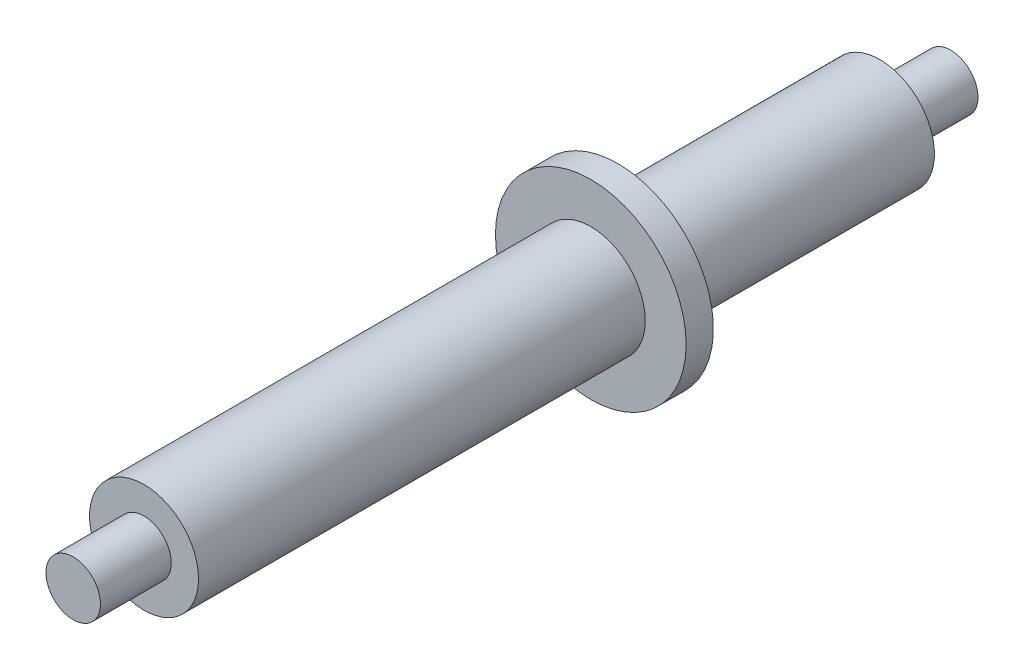
from build123d import *

# Parameters (mm, degrees)
EXTRUDE_START   = 3.386462
SKETCH_1_R      = 2
EXTRUDE_1_DEPTH = 27.013538
SKETCH_2_R      = 1
EXTRUDE_2_DEPTH = 2.6
SKETCH_4_R      = 1
EXTRUDE_3_DEPTH = 2.6
EXTRUDE_START_2 = -10.613538
SKETCH_6_R      = 3.5
EXTRUDE_5_DEPTH = 1


with BuildPart() as part:
    # Эскиз1 → Бобышка-Вытянуть1 (new body)
    with BuildSketch(Plane.XY.offset(EXTRUDE_START)):
        Circle(SKETCH_1_R)
    extrude(amount=EXTRUDE_1_DEPTH)

    # Эскиз2 → Бобышка-Вытянуть2 (add)
    with BuildSketch(Plane.XY.offset(30.4)):
        Circle(SKETCH_2_R)
    extrude(amount=EXTRUDE_2_DEPTH)

    # Эскиз4 → Бобышка-Вытянуть3 (add)
    with BuildSketch(Plane(origin=(0, 0, 3.386462289), x_dir=(-1, 0, 0), z_dir=(0, 0, -1))):
        Circle(SKETCH_4_R)
    extrude(amount=EXTRUDE_3_DEPTH)

    # Эскиз6 → Бобышка-Вытянуть5 (add)
    with BuildSketch(Plane(origin=(0, 0, 3.386462289), x_dir=(-1, 0, 0), z_dir=(0, 0, -1)).offset(EXTRUDE_START_2)):
        Circle(SKETCH_6_R)
    extrude(amount=EXTRUDE_5_DEPTH)


solid = part.part
